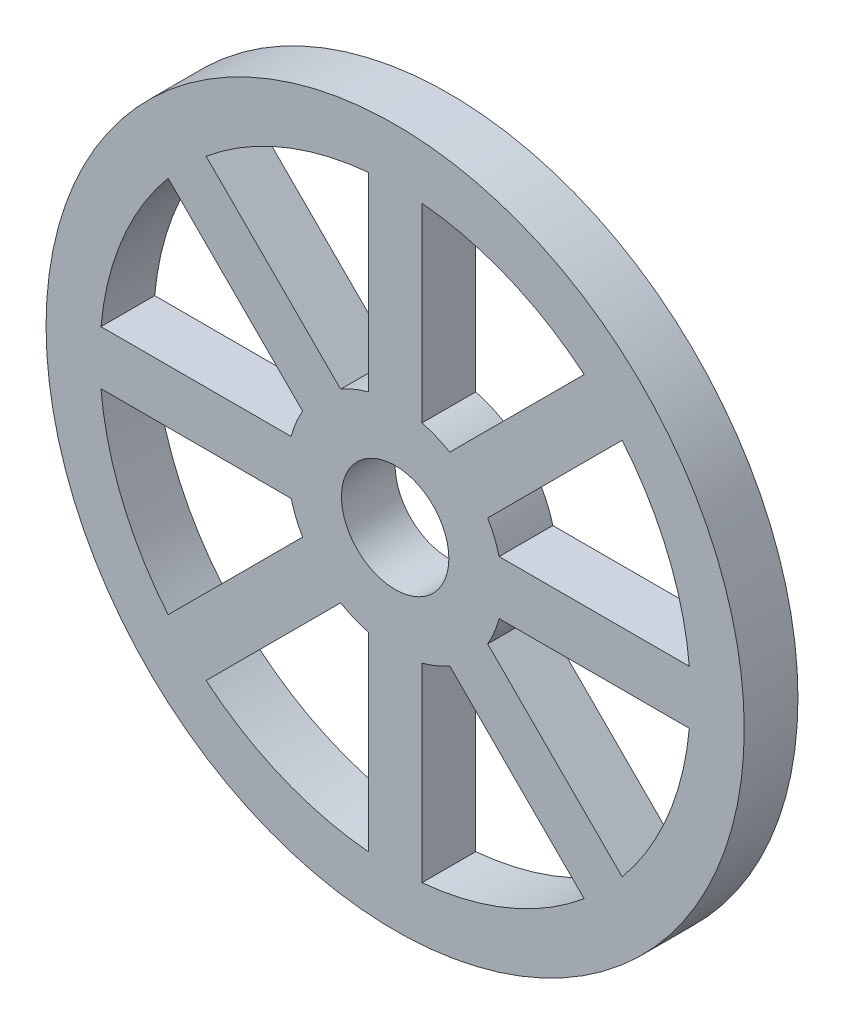
from build123d import *

# Parameters (mm, degrees)
SKIZZE1_R                       = 32.5
SKIZZE1_R_2                     = 5
AUFSATZ_LINEAR_AUSTRAGEN1_DEPTH = 5
SCHNITT_LINEAR_AUSTRAGEN1_DEPTH = 6
KREISMUSTER1_COUNT              = 8


with BuildPart() as part:
    # Skizze1 → Aufsatz-Linear austragen1 (new body)
    with BuildSketch(Plane.XY):
        Circle(SKIZZE1_R)
        Circle(SKIZZE1_R_2, mode=Mode.SUBTRACT)
    extrude(amount=-AUFSATZ_LINEAR_AUSTRAGEN1_DEPTH)

    # Skizze2 → Schnitt-Linear austragen1 (cut, through all)
    with BuildSketch(Plane.XY):
        with BuildLine():
            Line((2.5, 27.386127875), (2.5, 9.682458366))
            ThreePointArc((2.5, 9.682458366), (3.826834324, 9.238795325), (5.078765016, 8.614298922))
            Line((5.078765016, 8.614298922), (17.597149778, 21.132683684))
            ThreePointArc((17.597149778, 21.132683684), (10.52379439, 25.406687144), (2.5, 27.386127875))
        make_face()
    schnitt_linear_austragen1 = extrude(amount=-SCHNITT_LINEAR_AUSTRAGEN1_DEPTH, mode=Mode.SUBTRACT)

    # Kreismuster1: Schnitt-Linear austragen1 ×8 about axis
    kreismuster1_axis = Axis((0, 0, 0), (0, 0, 1))
    for i in range(1, KREISMUSTER1_COUNT):
        add(schnitt_linear_austragen1.rotate(kreismuster1_axis, i * 360 / KREISMUSTER1_COUNT), mode=Mode.SUBTRACT)


solid = part.part
